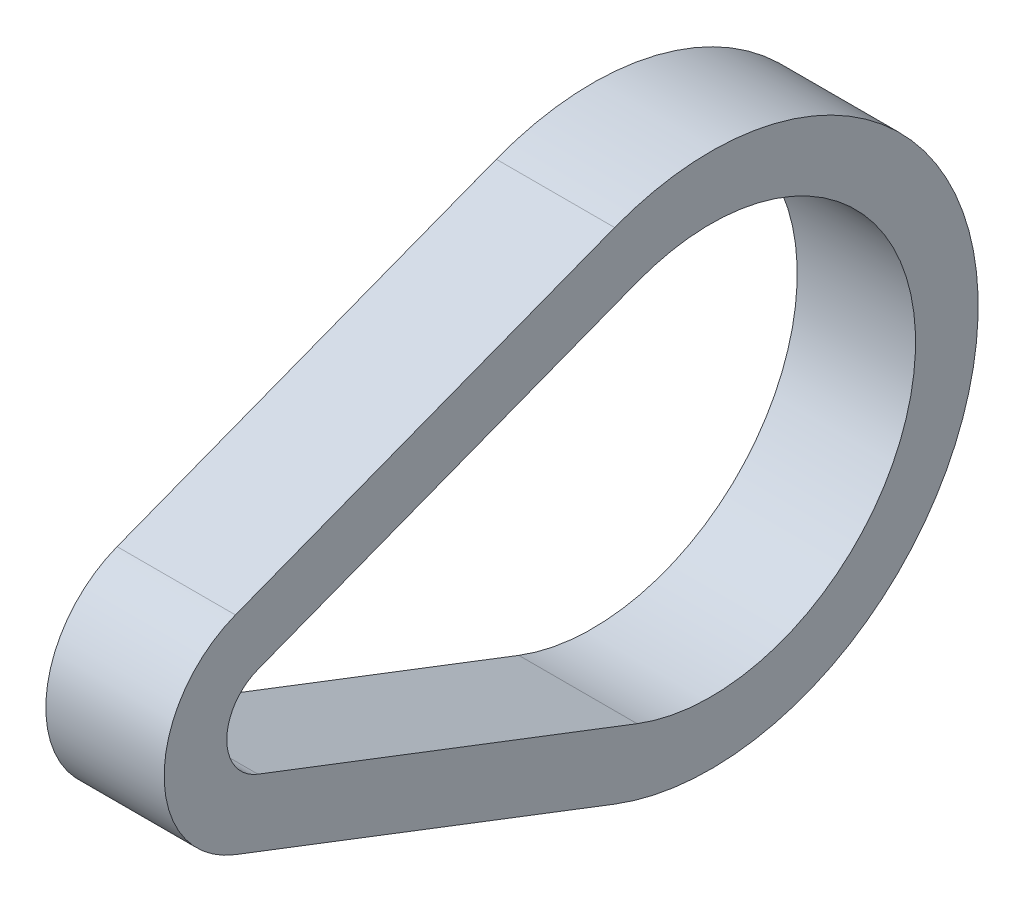
from build123d import *

# Parameters (mm, degrees)
BOSS_EXTRUDE1_DEPTH = 3


with BuildPart() as part:
    # Sketch1 → Boss-Extrude1 (new body, symmetric)
    with BuildSketch(Plane(origin=(0, 0, 0), x_dir=(0, 0, -1), z_dir=(1, 0, 0))):
        with BuildLine():
            Line((-2.024517376, 5.262831446), (17.20281496, 12.659243209))
            ThreePointArc((17.20281496, 12.659243209), (35.6362, 0), (17.20281496, -12.659243209))
            Line((17.20281496, -12.659243209), (-2.024517376, -5.262831446))
            ThreePointArc((-2.024517376, -5.262831446), (-5.6388, 0), (-2.024517376, 5.262831446))
        make_face()
        with BuildLine():
            Line((-0.884586421, 2.299525452), (18.342745915, 9.695937214))
            ThreePointArc((18.342745915, 9.695937214), (32.4612, 0), (18.342745915, -9.695937214))
            Line((18.342745915, -9.695937214), (-0.884586421, -2.299525452))
            ThreePointArc((-0.884586421, -2.299525452), (-2.4638, 0), (-0.884586421, 2.299525452))
        make_face(mode=Mode.SUBTRACT)
    extrude(amount=BOSS_EXTRUDE1_DEPTH, both=True)


solid = part.part
